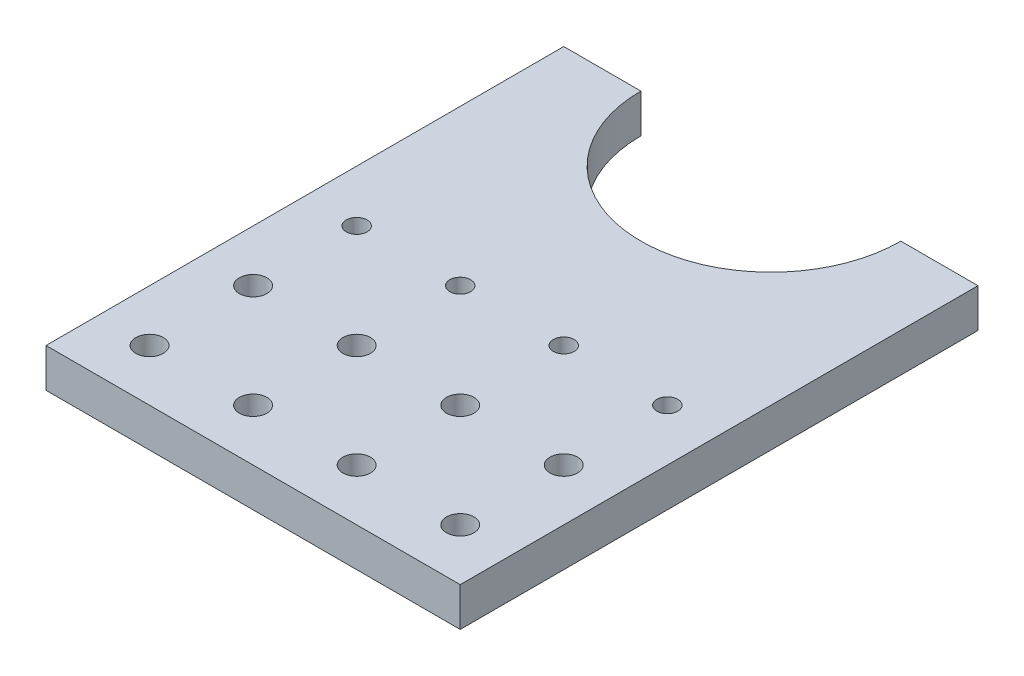
from build123d import *

# Parameters (mm, degrees)
SKETCH1_W                   = 101.6
SKETCH1_H                   = 127
BOSS_EXTRUDE1_DEPTH         = 9.525
SKETCH2_R                   = 31.877
CUT_EXTRUDE1_DEPTH          = 10.525
F_1_4_CLEARANCE_HOLE1_D     = 6.7564
LPATTERN1_COUNT             = 2
LPATTERN1_PITCH             = 25.4
LPATTERN1_COUNT_DIR2        = 4
LPATTERN1_PITCH_DIR2        = 25.4
TAP_DRILL_FOR_1_4_20_TAP1_D = 5.1054
LPATTERN2_COUNT             = 4
LPATTERN2_PITCH             = 25.4


with BuildPart() as part:
    # Sketch1 → Boss-Extrude1 (new body)
    with BuildSketch(Plane(origin=(0, 0, 0), x_dir=(1, 0, 0), z_dir=(0, 1, 0))):
        with Locations((50.8, 63.5)):
            Rectangle(SKETCH1_W, SKETCH1_H)
    extrude(amount=BOSS_EXTRUDE1_DEPTH)

    # Sketch2 → Cut-Extrude1 (cut, through all)
    with BuildSketch(Plane(origin=(0, 9.525, 0), x_dir=(1, 0, 0), z_dir=(0, 1, 0))):
        with Locations((50.8, 127)):
            Circle(SKETCH2_R)
    extrude(amount=-CUT_EXTRUDE1_DEPTH, mode=Mode.SUBTRACT)

    # 1/4 Clearance Hole1 (through all)
    with Locations(Plane(origin=(0, 9.525, 0), x_dir=(-1, 0, 0), z_dir=(0, 1, 0))):
        with Locations((-12.7, -12.7)):
            f_1_4_clearance_hole1 = Hole(F_1_4_CLEARANCE_HOLE1_D / 2)

    # LPattern1: 1_4 Clearance Hole1 2 × 4
    with Locations(*[(j * LPATTERN1_PITCH_DIR2, 0, -i * LPATTERN1_PITCH) for i in range(LPATTERN1_COUNT) for j in range(LPATTERN1_COUNT_DIR2) if (i, j) != (0, 0)]):
        add(f_1_4_clearance_hole1, mode=Mode.SUBTRACT)

    # Tap Drill for 1/4-20 Tap1 (through all)
    with Locations(Plane(origin=(0, 9.525, 0), x_dir=(-1, 0, 0), z_dir=(0, 1, 0))):
        with Locations((-12.7, -63.5)):
            tap_drill_for_1_4_20_tap1 = Hole(TAP_DRILL_FOR_1_4_20_TAP1_D / 2)

    # LPattern2: Tap Drill for 1/4-20 Tap1 ×4
    with Locations(*[(i * LPATTERN2_PITCH, 0, 0) for i in range(1, LPATTERN2_COUNT)]):
        add(tap_drill_for_1_4_20_tap1, mode=Mode.SUBTRACT)


solid = part.part
